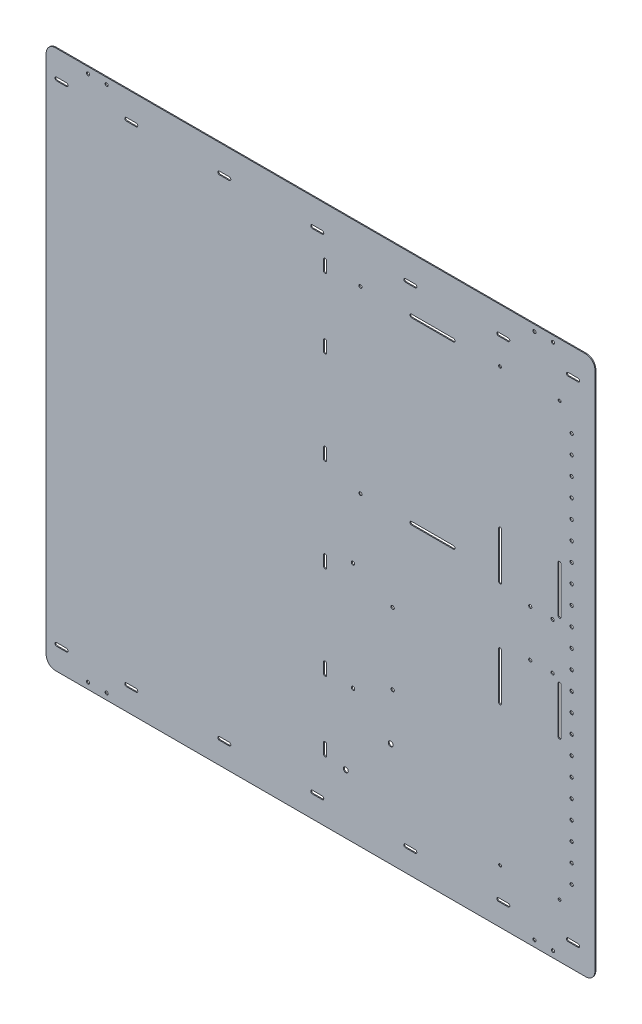
from build123d import *

# Parameters (mm, degrees)
SKETCH1_W                      = 590
SKETCH1_H                      = 580
BOSS_EXTRUDE1_DEPTH            = 1
M3_CLEARANCE_HOLE1_AT_2_COUNT  = 2
M3_CLEARANCE_HOLE1_AT_2_PITCH  = 566.87292262
M3_CLEARANCE_HOLE1_AT_3_COUNT  = 2
M3_CLEARANCE_HOLE1_AT_3_PITCH  = 480
M3_CLEARANCE_HOLE1_AT_4_COUNT  = 2
M3_CLEARANCE_HOLE1_AT_4_PITCH  = 742.526033483
M3_CLEARANCE_HOLE1_AT_5_COUNT  = 2
M3_CLEARANCE_HOLE1_AT_5_PITCH  = 20
M3_CLEARANCE_HOLE1_AT_6_COUNT  = 2
M3_CLEARANCE_HOLE1_AT_6_PITCH  = 460
M3_CLEARANCE_HOLE1_AT_7_COUNT  = 2
M3_CLEARANCE_HOLE1_AT_7_PITCH  = 729.756747417
M3_CLEARANCE_HOLE1_AT_8_COUNT  = 2
M3_CLEARANCE_HOLE1_AT_8_PITCH  = 566.52
FILLET1_R                      = 10
SKETCH9_R                      = 1.8
BMS_HOLES_DEPTH                = 2
WIRE_DUCT_HOLES_DEPTH          = 2
SKETCH12_R                     = 1.7
REMOTE_STOP_HOLES_DEPTH        = 2
SKETCH13_R                     = 1.5
MOTOR_DRIVER_STACK_HOLES_DEPTH = 2
SKETCH14_R                     = 1.7
POWER_CUBE_HOLES_DEPTH         = 2
SKETCH16_R                     = 1.75
FLEX_HOLES_DEPTH               = 2
SKETCH17_R                     = 2.65
CUT_EXTRUDE3_DEPTH             = 2


with BuildPart() as part:
    # Sketch1 → Boss-Extrude1 (new body)
    with BuildSketch(Plane.XY):
        Rectangle(SKETCH1_W, SKETCH1_H)
    extrude(amount=BOSS_EXTRUDE1_DEPTH)

    # Sketch8 → M3 Clearance Hole1 (revolve, cut)
    with BuildSketch(Plane(origin=(-230, 283.26, 0), x_dir=(0, 1, 0), z_dir=(1, 0, 0))):
        Polygon((0, 0), (0, 1), (1.7, 1), (1.7, 0.025), (1.725, 0), align=None)
    m3_clearance_hole1 = revolve(axis=Axis((-230, 283.26, -6.35), (0, 0, 1)), mode=Mode.SUBTRACT)

    # M3 Clearance Hole1 at 2: M3 Clearance Hole1 ×2
    with Locations(*[Vector(-0.035281276, -0.999377422, 0) * (i * M3_CLEARANCE_HOLE1_AT_2_PITCH) for i in range(1, M3_CLEARANCE_HOLE1_AT_2_COUNT)]):
        add(m3_clearance_hole1, mode=Mode.SUBTRACT)

    # M3 Clearance Hole1 at 3: M3 Clearance Hole1 ×2
    with Locations(*[(i * M3_CLEARANCE_HOLE1_AT_3_PITCH, 0, 0) for i in range(1, M3_CLEARANCE_HOLE1_AT_3_COUNT)]):
        add(m3_clearance_hole1, mode=Mode.SUBTRACT)

    # M3 Clearance Hole1 at 4: M3 Clearance Hole1 ×2
    with Locations(*[Vector(0.646441981, -0.762963148, 0) * (i * M3_CLEARANCE_HOLE1_AT_4_PITCH) for i in range(1, M3_CLEARANCE_HOLE1_AT_4_COUNT)]):
        add(m3_clearance_hole1, mode=Mode.SUBTRACT)

    # M3 Clearance Hole1 at 5: M3 Clearance Hole1 ×2
    with Locations(*[(-i * M3_CLEARANCE_HOLE1_AT_5_PITCH, 0, 0) for i in range(1, M3_CLEARANCE_HOLE1_AT_5_COUNT)]):
        add(m3_clearance_hole1, mode=Mode.SUBTRACT)

    # M3 Clearance Hole1 at 6: M3 Clearance Hole1 ×2
    with Locations(*[(i * M3_CLEARANCE_HOLE1_AT_6_PITCH, 0, 0) for i in range(1, M3_CLEARANCE_HOLE1_AT_6_COUNT)]):
        add(m3_clearance_hole1, mode=Mode.SUBTRACT)

    # M3 Clearance Hole1 at 7: M3 Clearance Hole1 ×2
    with Locations(*[Vector(0.630347032, -0.77631348, 0) * (i * M3_CLEARANCE_HOLE1_AT_7_PITCH) for i in range(1, M3_CLEARANCE_HOLE1_AT_7_COUNT)]):
        add(m3_clearance_hole1, mode=Mode.SUBTRACT)

    # M3 Clearance Hole1 at 8: M3 Clearance Hole1 ×2
    with Locations(*[(0, -i * M3_CLEARANCE_HOLE1_AT_8_PITCH, 0) for i in range(1, M3_CLEARANCE_HOLE1_AT_8_COUNT)]):
        add(m3_clearance_hole1, mode=Mode.SUBTRACT)

    # Fillet1
    fillet1_edges = [part.edges().sort_by_distance(p)[0] for p in [
        (295, -290, 0.5),
        (-295, -290, 0.5),
        (-295, 290, 0.5),
        (295, 290, 0.5),
    ]]
    fillet(fillet1_edges, radius=FILLET1_R)

    # Sketch9 → BMS Holes (cut, through all)
    with BuildSketch(Plane.XY):
        with Locations((77.5, -126.46)):
            Circle(SKETCH9_R)
        with Locations((77.5, -49.96)):
            Circle(SKETCH9_R)
        with Locations((34.9, -29.96)):
            Circle(SKETCH9_R)
        with Locations((34.9, -146.46)):
            Circle(SKETCH9_R)
    extrude(amount=BMS_HOLES_DEPTH, mode=Mode.SUBTRACT)

    # Sketch10 → Wire Duct Holes (cut, through all)
    with BuildSketch(Plane.XY.offset(1)):
        with BuildLine():
            Line((-208.75, 263.31), (-198.25, 263.31))
            ThreePointArc((-198.25, 263.31), (-196.5, 261.56), (-198.25, 259.81))
            Line((-198.25, 259.81), (-208.75, 259.81))
            ThreePointArc((-208.75, 259.81), (-210.5, 261.56), (-208.75, 263.31))
        make_face()
        with BuildLine():
            Line((-108.75, 263.31), (-98.25, 263.31))
            ThreePointArc((-98.25, 263.31), (-96.5, 261.56), (-98.25, 259.81))
            Line((-98.25, 259.81), (-108.75, 259.81))
            ThreePointArc((-108.75, 259.81), (-110.5, 261.56), (-108.75, 263.31))
        make_face()
        with BuildLine():
            Line((-8.75, 263.31), (1.75, 263.31))
            ThreePointArc((1.75, 263.31), (3.5, 261.56), (1.75, 259.81))
            Line((1.75, 259.81), (-8.75, 259.81))
            ThreePointArc((-8.75, 259.81), (-10.5, 261.56), (-8.75, 263.31))
        make_face()
        with BuildLine():
            Line((91.25, 263.31), (101.75, 263.31))
            ThreePointArc((101.75, 263.31), (103.5, 261.56), (101.75, 259.81))
            Line((101.75, 259.81), (91.25, 259.81))
            ThreePointArc((91.25, 259.81), (89.5, 261.56), (91.25, 263.31))
        make_face()
        with BuildLine():
            Line((191.25, 263.31), (201.75, 263.31))
            ThreePointArc((201.75, 263.31), (203.5, 261.56), (201.75, 259.81))
            Line((201.75, 259.81), (191.25, 259.81))
            ThreePointArc((191.25, 259.81), (189.5, 261.56), (191.25, 263.31))
        make_face()
        with BuildLine():
            Line((-108.75, -263.21), (-98.25, -263.21))
            ThreePointArc((-98.25, -263.21), (-96.5, -264.96), (-98.25, -266.71))
            Line((-98.25, -266.71), (-108.75, -266.71))
            ThreePointArc((-108.75, -266.71), (-110.5, -264.96), (-108.75, -263.21))
        make_face()
        with BuildLine():
            Line((-8.75, -263.21), (1.75, -263.21))
            ThreePointArc((1.75, -263.21), (3.5, -264.96), (1.75, -266.71))
            Line((1.75, -266.71), (-8.75, -266.71))
            ThreePointArc((-8.75, -266.71), (-10.5, -264.96), (-8.75, -263.21))
        make_face()
        with BuildLine():
            Line((91.25, -263.21), (101.75, -263.21))
            ThreePointArc((101.75, -263.21), (103.5, -264.96), (101.75, -266.71))
            Line((101.75, -266.71), (91.25, -266.71))
            ThreePointArc((91.25, -266.71), (89.5, -264.96), (91.25, -263.21))
        make_face()
        with BuildLine():
            Line((191.25, -263.21), (201.75, -263.21))
            ThreePointArc((201.75, -263.21), (203.5, -264.96), (201.75, -266.71))
            Line((201.75, -266.71), (191.25, -266.71))
            ThreePointArc((191.25, -266.71), (189.5, -264.96), (191.25, -263.21))
        make_face()
        with BuildLine():
            Line((-208.75, -263.21), (-198.25, -263.21))
            ThreePointArc((-198.25, -263.21), (-196.5, -264.96), (-198.25, -266.71))
            Line((-198.25, -266.71), (-208.75, -266.71))
            ThreePointArc((-208.75, -266.71), (-210.5, -264.96), (-208.75, -263.21))
        make_face()
        with BuildLine():
            Line((-283.75, 263.31), (-273.25, 263.31))
            ThreePointArc((-273.25, 263.31), (-271.5, 261.56), (-273.25, 259.81))
            Line((-273.25, 259.81), (-283.75, 259.81))
            ThreePointArc((-283.75, 259.81), (-285.5, 261.56), (-283.75, 263.31))
        make_face()
        with BuildLine():
            Line((266.25, 263.31), (276.75, 263.31))
            ThreePointArc((276.75, 263.31), (278.5, 261.56), (276.75, 259.81))
            Line((276.75, 259.81), (266.25, 259.81))
            ThreePointArc((266.25, 259.81), (264.5, 261.56), (266.25, 263.31))
        make_face()
        with BuildLine():
            Line((266.25, -263.21), (276.75, -263.21))
            ThreePointArc((276.75, -263.21), (278.5, -264.96), (276.75, -266.71))
            Line((276.75, -266.71), (266.25, -266.71))
            ThreePointArc((266.25, -266.71), (264.5, -264.96), (266.25, -263.21))
        make_face()
        with BuildLine():
            Line((-283.75, -263.21), (-273.25, -263.21))
            ThreePointArc((-273.25, -263.21), (-271.5, -264.96), (-273.25, -266.71))
            Line((-273.25, -266.71), (-283.75, -266.71))
            ThreePointArc((-283.75, -266.71), (-285.5, -264.96), (-283.75, -263.21))
        make_face()
        with BuildLine():
            Line((6.65, 162.1), (6.65, 151.6))
            ThreePointArc((6.65, 151.6), (4.9, 149.85), (3.15, 151.6))
            Line((3.15, 151.6), (3.15, 162.1))
            ThreePointArc((3.15, 162.1), (4.9, 163.85), (6.65, 162.1))
        make_face()
        with BuildLine():
            Line((6.65, 62.1), (6.65, 51.6))
            ThreePointArc((6.65, 51.6), (4.9, 49.85), (3.15, 51.6))
            Line((3.15, 51.6), (3.15, 62.1))
            ThreePointArc((3.15, 62.1), (4.9, 63.85), (6.65, 62.1))
        make_face()
        with BuildLine():
            Line((6.65, -37.9), (6.65, -48.4))
            ThreePointArc((6.65, -48.4), (4.9, -50.15), (3.15, -48.4))
            Line((3.15, -48.4), (3.15, -37.9))
            ThreePointArc((3.15, -37.9), (4.9, -36.15), (6.65, -37.9))
        make_face()
        with BuildLine():
            Line((6.65, -137.9), (6.65, -148.4))
            ThreePointArc((6.65, -148.4), (4.9, -150.15), (3.15, -148.4))
            Line((3.15, -148.4), (3.15, -137.9))
            ThreePointArc((3.15, -137.9), (4.9, -136.15), (6.65, -137.9))
        make_face()
        with BuildLine():
            Line((6.65, 237.1), (6.65, 226.6))
            ThreePointArc((6.65, 226.6), (4.9, 224.85), (3.15, 226.6))
            Line((3.15, 226.6), (3.15, 237.1))
            ThreePointArc((3.15, 237.1), (4.9, 238.85), (6.65, 237.1))
        make_face()
        with BuildLine():
            Line((6.65, -212.9), (6.65, -223.4))
            ThreePointArc((6.65, -223.4), (4.9, -225.15), (3.15, -223.4))
            Line((3.15, -223.4), (3.15, -212.9))
            ThreePointArc((3.15, -212.9), (4.9, -211.15), (6.65, -212.9))
        make_face()
    extrude(amount=-WIRE_DUCT_HOLES_DEPTH, mode=Mode.SUBTRACT)

    # Sketch12 → Remote Stop Holes (cut, through all)
    with BuildSketch(Plane(origin=(0, 0, 0), x_dir=(-1, 0, 0), z_dir=(0, 0, -1))):
        with Locations((-249.5, -25)):
            Circle(SKETCH12_R)
        with Locations((-225.5, -25)):
            Circle(SKETCH12_R)
        with Locations((-249.5, 25)):
            Circle(SKETCH12_R)
        with Locations((-225.5, 25)):
            Circle(SKETCH12_R)
    extrude(amount=-REMOTE_STOP_HOLES_DEPTH, mode=Mode.SUBTRACT)

    # Sketch13 → Motor Driver Stack Holes (cut, through all)
    with BuildSketch(Plane(origin=(0, 0, 0), x_dir=(-1, 0, 0), z_dir=(0, 0, -1))):
        with Locations((-257, 232.26)):
            Circle(SKETCH13_R)
        with Locations((-193, 232.26)):
            Circle(SKETCH13_R)
        with Locations((-193, -232.26)):
            Circle(SKETCH13_R)
        with Locations((-257, -232.26)):
            Circle(SKETCH13_R)
        with BuildLine():
            Line((-258.5, 31.26), (-258.5, 81.26))
            ThreePointArc((-258.5, 81.26), (-257, 82.76), (-255.5, 81.26))
            Line((-255.5, 81.26), (-255.5, 31.26))
            ThreePointArc((-255.5, 31.26), (-257, 29.76), (-258.5, 31.26))
        make_face()
        with BuildLine():
            Line((-194.5, 31.26), (-194.5, 81.26))
            ThreePointArc((-194.5, 81.26), (-193, 82.76), (-191.5, 81.26))
            Line((-191.5, 81.26), (-191.5, 31.26))
            ThreePointArc((-191.5, 31.26), (-193, 29.76), (-194.5, 31.26))
        make_face()
        with BuildLine():
            Line((-194.5, -31.26), (-194.5, -81.26))
            ThreePointArc((-194.5, -81.26), (-193, -82.76), (-191.5, -81.26))
            Line((-191.5, -81.26), (-191.5, -31.26))
            ThreePointArc((-191.5, -31.26), (-193, -29.76), (-194.5, -31.26))
        make_face()
        with BuildLine():
            Line((-258.5, -31.26), (-258.5, -81.26))
            ThreePointArc((-258.5, -81.26), (-257, -82.76), (-255.5, -81.26))
            Line((-255.5, -81.26), (-255.5, -31.26))
            ThreePointArc((-255.5, -31.26), (-257, -29.76), (-258.5, -31.26))
        make_face()
    extrude(amount=-MOTOR_DRIVER_STACK_HOLES_DEPTH, mode=Mode.SUBTRACT)

    # Sketch14 → Power Cube Holes (cut, through all)
    with BuildSketch(Plane(origin=(0, 0, 0), x_dir=(-1, 0, 0), z_dir=(0, 0, -1))):
        with Locations((-42.9, 38.74)):
            Circle(SKETCH14_R)
        with Locations((-42.9, 231.74)):
            Circle(SKETCH14_R)
        with BuildLine():
            Line((-142.9, 233.44), (-97.9, 233.44))
            ThreePointArc((-97.9, 233.44), (-96.2, 231.74), (-97.9, 230.04))
            Line((-97.9, 230.04), (-142.9, 230.04))
            ThreePointArc((-142.9, 230.04), (-144.6, 231.74), (-142.9, 233.44))
        make_face()
        with BuildLine():
            Line((-142.9, 40.44), (-97.9, 40.44))
            ThreePointArc((-97.9, 40.44), (-96.2, 38.74), (-97.9, 37.04))
            Line((-97.9, 37.04), (-142.9, 37.04))
            ThreePointArc((-142.9, 37.04), (-144.6, 38.74), (-142.9, 40.44))
        make_face()
    extrude(amount=-POWER_CUBE_HOLES_DEPTH, mode=Mode.SUBTRACT)

    # Sketch16 → Flex Holes (cut, through all)
    with BuildSketch(Plane(origin=(0, 0, 0), x_dir=(-1, 0, 0), z_dir=(0, 0, -1))):
        with Locations((-270, -211.7)):
            Circle(SKETCH16_R)
        with Locations((-270, -191.7)):
            Circle(SKETCH16_R)
        with Locations((-270, -171.7)):
            Circle(SKETCH16_R)
        with Locations((-270, -151.7)):
            Circle(SKETCH16_R)
        with Locations((-270, -131.7)):
            Circle(SKETCH16_R)
        with Locations((-270, -111.7)):
            Circle(SKETCH16_R)
        with Locations((-270, -91.7)):
            Circle(SKETCH16_R)
        with Locations((-270, -71.7)):
            Circle(SKETCH16_R)
        with Locations((-270, -51.7)):
            Circle(SKETCH16_R)
        with Locations((-270, -31.7)):
            Circle(SKETCH16_R)
        with Locations((-270, -11.7)):
            Circle(SKETCH16_R)
        with Locations((-270, 8.3)):
            Circle(SKETCH16_R)
        with Locations((-270, 28.3)):
            Circle(SKETCH16_R)
        with Locations((-270, 48.3)):
            Circle(SKETCH16_R)
        with Locations((-270, 68.3)):
            Circle(SKETCH16_R)
        with Locations((-270, 88.3)):
            Circle(SKETCH16_R)
        with Locations((-270, 108.3)):
            Circle(SKETCH16_R)
        with Locations((-270, 128.3)):
            Circle(SKETCH16_R)
        with Locations((-270, 148.3)):
            Circle(SKETCH16_R)
        with Locations((-270, 168.3)):
            Circle(SKETCH16_R)
        with Locations((-270, 188.3)):
            Circle(SKETCH16_R)
        with Locations((-270, 208.3)):
            Circle(SKETCH16_R)
    extrude(amount=-FLEX_HOLES_DEPTH, mode=Mode.SUBTRACT)

    # Sketch17 → Cut-Extrude3 (cut, through all)
    with BuildSketch(Plane(origin=(0, 0, 0), x_dir=(-1, 0, 0), z_dir=(0, 0, -1))):
        with Locations((-75.5, -177.94482912)):
            Circle(SKETCH17_R)
        with Locations((-27.186222069, -226.258607052)):
            Circle(SKETCH17_R)
    extrude(amount=-CUT_EXTRUDE3_DEPTH, mode=Mode.SUBTRACT)


solid = part.part
